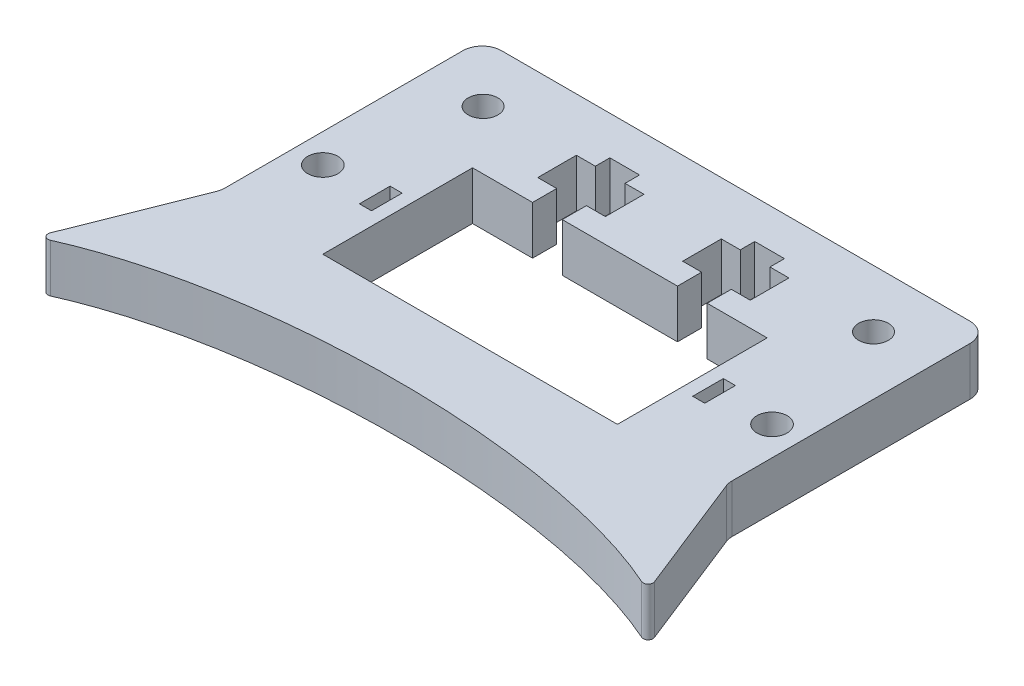
from build123d import *

# Parameters (mm, degrees)
SKETCH1_W           = 105
SKETCH1_H           = 70
BOSS_EXTRUDE1_DEPTH = 10
SKETCH2_W           = 61
SKETCH2_H           = 31
CUT_EXTRUDE1_DEPTH  = 11
SKETCH3_W           = 6.15
SKETCH3_H           = 5
SKETCH3_H_2         = 3
CUT_EXTRUDE2_DEPTH  = 10
SKETCH4_R           = 3.125
SKETCH4_W           = 2.5
SKETCH4_H           = 6.35
CUT_EXTRUDE3_DEPTH  = 11
BOSS_EXTRUDE2_DEPTH = 10
SKETCH6_R           = 3.075
CUT_EXTRUDE4_DEPTH  = 11.0000001
FILLET2_R           = 1
FILLET1_R           = 4


with BuildPart() as part:
    # Sketch1 → Boss-Extrude1 (new body)
    with BuildSketch(Plane(origin=(0, 0, 0), x_dir=(1, 0, 0), z_dir=(0, 1, 0))):
        Rectangle(SKETCH1_W, SKETCH1_H)
    extrude(amount=BOSS_EXTRUDE1_DEPTH)

    # Sketch2 → Cut-Extrude1 (cut, through all)
    with BuildSketch(Plane(origin=(0, 10, 0), x_dir=(1, 0, 0), z_dir=(0, 1, 0))):
        with Locations((0, -4.5)):
            Rectangle(SKETCH2_W, SKETCH2_H)
    extrude(amount=-CUT_EXTRUDE1_DEPTH, mode=Mode.SUBTRACT)

    # Sketch3 → Cut-Extrude2 (cut)
    with BuildSketch(Plane(origin=(0, 10, 0), x_dir=(1, 0, 0), z_dir=(0, 1, 0))):
        with Locations((-15, 13.5)):
            Rectangle(SKETCH3_W, SKETCH3_H)
        Polygon((-18.075, 24), (-22, 24), (-22, 16), (-18.075, 16), (-11.925, 16), (-8, 16), (-8, 24), (-11.925, 24), (-11.925, 21), (-18.075, 21), align=None)
        with Locations((-15, 22.5)):
            Rectangle(SKETCH3_W, SKETCH3_H_2)
        with Locations((-15, 25.5)):
            Rectangle(SKETCH3_W, SKETCH3_H_2)
    cut_extrude2 = extrude(amount=-CUT_EXTRUDE2_DEPTH, mode=Mode.SUBTRACT)

    # Sketch4 → Cut-Extrude3 (cut, through all)
    with BuildSketch(Plane(origin=(0, 10, 0), x_dir=(1, 0, 0), z_dir=(0, 1, 0))):
        with Locations((-46.5, -4)):
            Circle(SKETCH4_R)
        with Locations((-34.5, -4)):
            Rectangle(SKETCH4_W, SKETCH4_H)
    cut_extrude3 = extrude(amount=-CUT_EXTRUDE3_DEPTH, mode=Mode.SUBTRACT)

    # Sketch5 → Boss-Extrude2 (add)
    with BuildSketch(Plane(origin=(0, 0, 0), x_dir=(1, 0, 0), z_dir=(0, 1, 0))):
        with BuildLine():
            Line((0, -35), (-52.5, -19.039128985))
            Line((-52.5, -19.039128985), (-63.478993436, -46.742400328))
            add(Edge.make_bspline(
                [(0, -35), (-39.462588608, -35), (-63.478993436, -46.742400328)],
                knots=[4.71238898, 4.71238898, 4.71238898, 5.628907116, 5.628907116, 5.628907116], degree=2, weights=[1, 0.896824023, 1]))
        make_face()
    boss_extrude2 = extrude(amount=BOSS_EXTRUDE2_DEPTH)

    # Sketch6 → Cut-Extrude4 (cut, through all)
    with BuildSketch(Plane(origin=(0, 10, 0), x_dir=(1, 0, 0), z_dir=(0, 1, 0))):
        with Locations((-40.420875644, 23.095045258)):
            Circle(SKETCH6_R)
    cut_extrude4 = extrude(amount=-CUT_EXTRUDE4_DEPTH, mode=Mode.SUBTRACT)

    # Mirror1: Cut-Extrude2, Cut-Extrude3, Boss-Extrude2, Cut-Extrude4 across plane
    add(cut_extrude2.mirror(Plane(origin=(0, 0, 0), x_dir=(0, 0, 1), z_dir=(1, 0, 0))), mode=Mode.SUBTRACT)
    add(cut_extrude3.mirror(Plane(origin=(0, 0, 0), x_dir=(0, 0, 1), z_dir=(1, 0, 0))), mode=Mode.SUBTRACT)
    add(boss_extrude2.mirror(Plane(origin=(0, 0, 0), x_dir=(0, 0, 1), z_dir=(1, 0, 0))))
    add(cut_extrude4.mirror(Plane(origin=(0, 0, 0), x_dir=(0, 0, 1), z_dir=(1, 0, 0))), mode=Mode.SUBTRACT)

    # Fillet2
    fillet2_edges = [part.edges().sort_by_distance(p)[0] for p in [
        (-63.478993436, 5, 46.742400328),
        (63.478993436, 5, 46.742400328),
    ]]
    fillet(fillet2_edges, radius=FILLET2_R)

    # Fillet1
    fillet1_edges = [part.edges().sort_by_distance(p)[0] for p in [
        (52.5, 5, 19.039128985),
        (-52.5, 5, -35),
        (52.5, 5, -35),
        (-52.5, 5, 19.039128985),
    ]]
    fillet(fillet1_edges, radius=FILLET1_R)


solid = part.part
